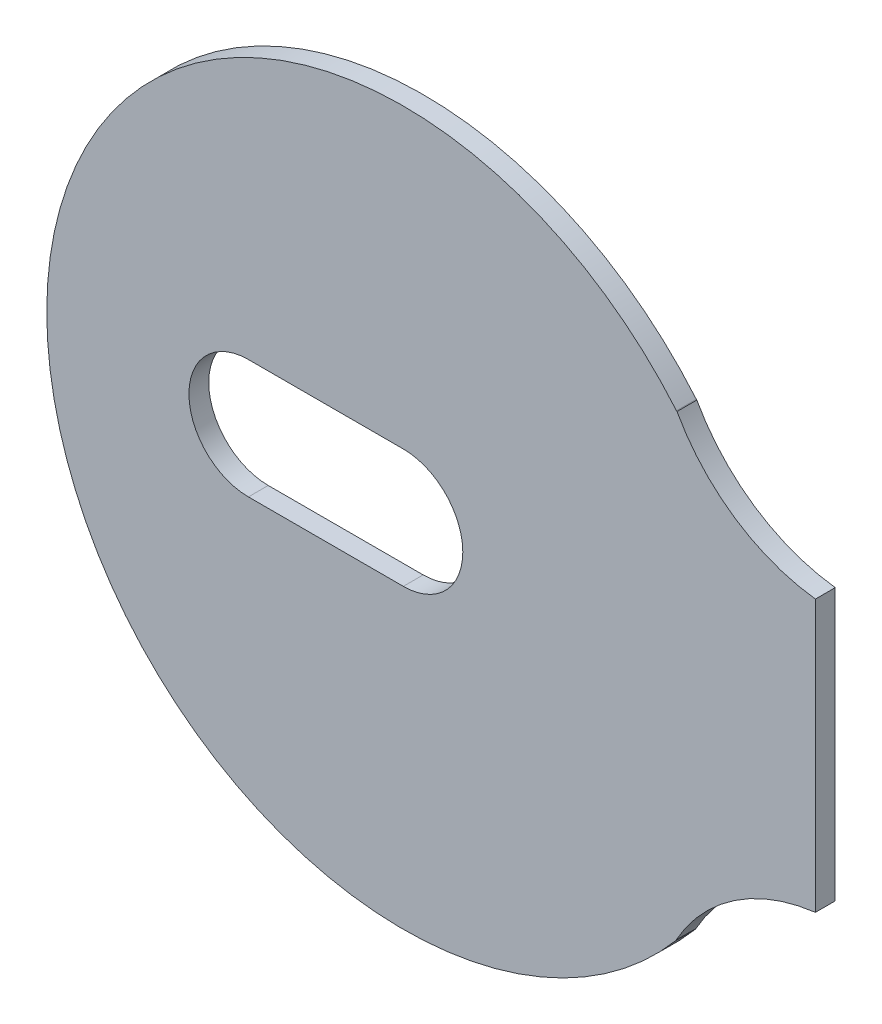
from build123d import *

# Parameters (mm, degrees)
EXTRUDE_1_DEPTH = 1


with BuildPart() as part:
    # 草图1 → 凸台-拉伸1 (new body)
    with BuildSketch(Plane.XY):
        with BuildLine():
            Line((13.756161337, -11.589316843), (13.755737728, -11.576233912))
            ThreePointArc((13.755737728, -11.576233912), (16.705777817, -8.371391827), (20.787340615, -6.8500127))
            Line((20.787340615, -6.8500127), (20.787340615, 6.838712609))
            ThreePointArc((20.787340615, 6.838712609), (16.726466447, 8.343658429), (13.805099755, 11.540716072))
            Line((13.805099755, 11.540716072), (13.780842765, 11.560323903))
            Line((13.780842765, 11.560323903), (13.779097734, 11.562037241))
            ThreePointArc((13.779097734, 11.562037241), (-17.987329683, 0.017820318), (13.756161337, -11.589316843))
        make_face()
        with BuildLine():
            Line((-7.815615951, 3.00000508), (0, 3.00000508))
            ThreePointArc((0, 3.00000508), (3.000005067, 1.3e-08), (0, -3.000005054))
            Line((0, -3.000005054), (-7.815615951, -3.000005054))
            ThreePointArc((-7.815615951, -3.000005054), (-10.816019825, 1.3e-08), (-7.815615951, 3.00000508))
        make_face(mode=Mode.SUBTRACT)
    extrude(amount=EXTRUDE_1_DEPTH)


solid = part.part
